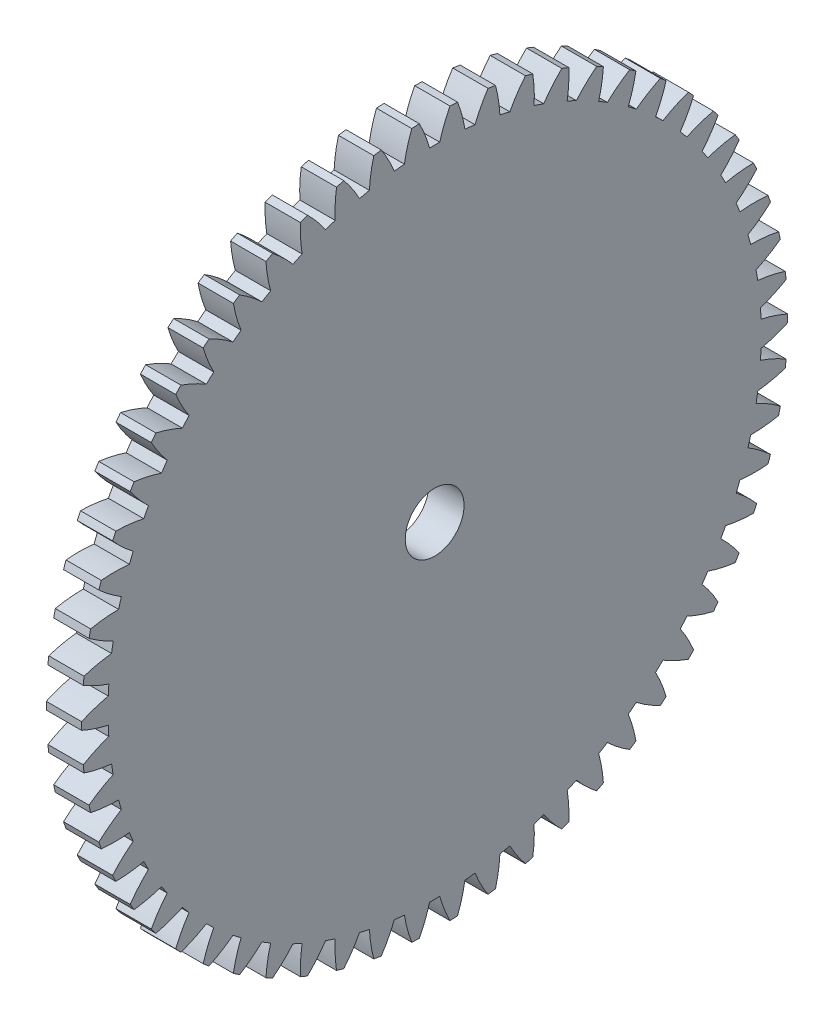
from build123d import *

# Parameters (mm, degrees)
BASPROSKE_W     = 3
BASPROSKE_H     = 30
TOOTHCUT_DEPTH  = 43.532340636
TEETHCUTS_COUNT = 58
TEETHCUTS_ANGLE = 353.793103448
BORSKE_R        = 2.5
BORE_DEPTH      = 50.0000508


with BuildPart() as part:
    # BasProSke → Base-Revolve (revolve)
    with BuildSketch(Plane(origin=(0, 0, 0), x_dir=(1, 0, 0), z_dir=(0, 1, 0)), mode=Mode.PRIVATE) as base_revolve_sk:
        with Locations((1.5, 15)):
            Rectangle(BASPROSKE_W, BASPROSKE_H)
    revolve(base_revolve_sk.sketch.rotate(Axis((-10, 0, 0), (1, 0, 0)), 180), axis=Axis((-10, 0, 0), (1, 0, 0)))

    # TooCutSke → ToothCut (cut, through all)
    with BuildSketch(Plane(origin=(0, 0, 0), x_dir=(0, 0, -1), z_dir=(1, 0, 0))):
        with BuildLine():
            ThreePointArc((0.431457278, 27.745645525), (0, 27.749), (-0.431457278, 27.745645525))
            ThreePointArc((-0.431457278, 27.745645525), (-0.814693207, 28.894207795), (-1.315565323, 29.996565354))
            ThreePointArc((-1.315565323, 29.996565354), (0, 30.0254), (1.315565323, 29.996565354))
            ThreePointArc((1.315565323, 29.996565354), (0.814693207, 28.894207795), (0.431457278, 27.745645525))
        make_face()
    toothcut = extrude(amount=TOOTHCUT_DEPTH, mode=Mode.SUBTRACT)

    # TeethCuts: ToothCut ×58 about axis
    teethcuts_axis = Axis((-10, 0, 0), (1, 0, 0))
    for i in range(1, TEETHCUTS_COUNT):
        add(toothcut.rotate(teethcuts_axis, i * TEETHCUTS_ANGLE / (TEETHCUTS_COUNT - 1)), mode=Mode.SUBTRACT)

    # BorSke → Bore (cut, symmetric)
    with BuildSketch(Plane(origin=(0, 0, 0), x_dir=(0, 0, -1), z_dir=(1, 0, 0))):
        with Locations(Location((0, 0, 0), (0, 0, 180))):
            Circle(BORSKE_R)
    extrude(amount=BORE_DEPTH, both=True, mode=Mode.SUBTRACT)


solid = part.part
